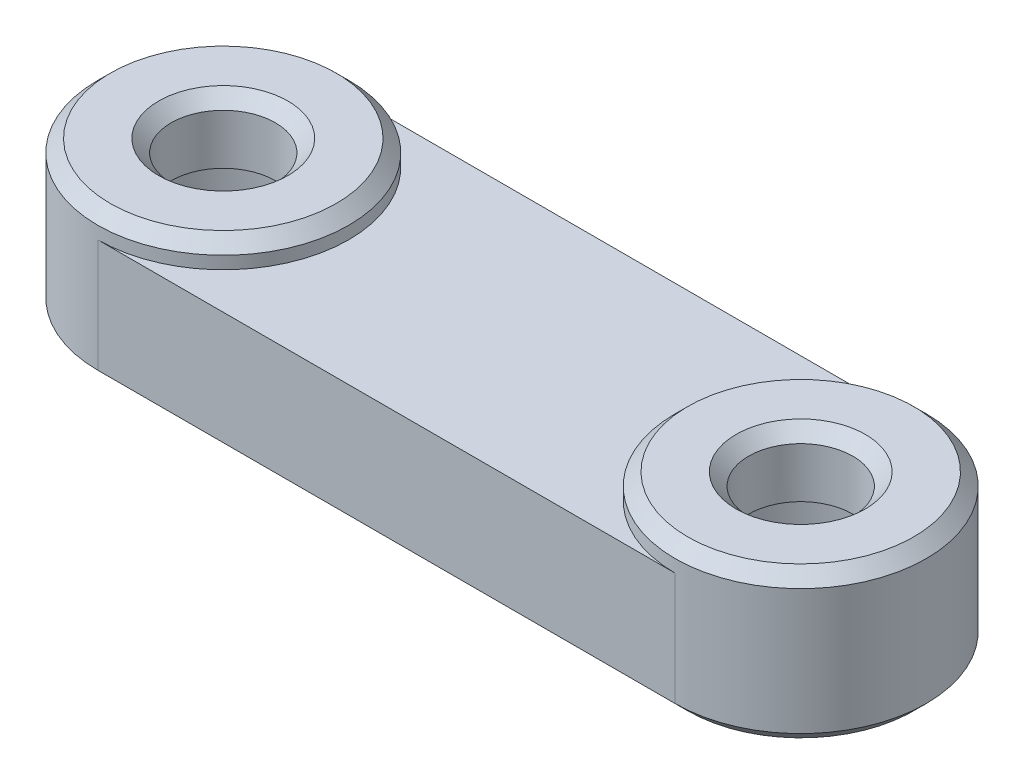
from build123d import *

# Parameters (mm, degrees)
BOSS_EXTRUDE1_DEPTH = 6
SKETCH5_W           = 50.780974492
SKETCH5_H           = 22.085020173
SKETCH5_R           = 5
CUT_EXTRUDE1_DEPTH  = 1
CHAMFER2_SIZE       = 0.5


with BuildPart() as part:
    # Sketch2 → Boss-Extrude1 (new body)
    with BuildSketch(Plane(origin=(0, 0, 0), x_dir=(1, 0, 0), z_dir=(0, 1, 0))):
        with BuildLine():
            Line((0, 5), (23, 5))
            ThreePointArc((23, 5), (28, 0), (23, -5))
            Line((23, -5), (0, -5))
            ThreePointArc((0, -5), (-5, 0), (0, 5))
        make_face()
    extrude(amount=BOSS_EXTRUDE1_DEPTH)

    # Sketch3 → Cut-Revolve1 (revolve, cut)
    with BuildSketch(Plane.XY):
        Polygon((0, 0), (-3.75, 0), (-3.75, 3.5), (-2.075, 3.5), (-2.075, 6), (0, 6), align=None)
    revolve(axis=Axis((0, 0, 0), (0, 1, 0)), mode=Mode.SUBTRACT)

    # Sketch4 → Cut-Revolve2 (revolve, cut)
    with BuildSketch(Plane.XY):
        Polygon((23, 0), (19.25, 0), (19.25, 3.5), (20.925, 3.5), (20.925, 6), (23, 6), align=None)
    revolve(axis=Axis((23, 0, 0), (0, 1, 0)), mode=Mode.SUBTRACT)

    # Sketch5 → Cut-Extrude1 (cut)
    with BuildSketch(Plane(origin=(0, 6, 0), x_dir=(1, 0, 0), z_dir=(0, 1, 0))):
        with Locations((10.314830551, 0.079491573)):
            Rectangle(SKETCH5_W, SKETCH5_H)
        Circle(SKETCH5_R, mode=Mode.SUBTRACT)
        with Locations((23, 0)):
            Circle(SKETCH5_R, mode=Mode.SUBTRACT)
    extrude(amount=-CUT_EXTRUDE1_DEPTH, mode=Mode.SUBTRACT)

    # Chamfer2
    chamfer2_edges = [part.edges().sort_by_distance(p)[0] for p in [
        (23, 6, 5),
        (2.075, 6, 0),
        (25.075, 6, 0),
        (-5, 6, 0),
        (11.5, 0, -5),
        (28, 0, 0),
        (11.5, 0, 5),
        (-5, 0, 0),
    ]]
    chamfer(chamfer2_edges, length=CHAMFER2_SIZE)


solid = part.part
